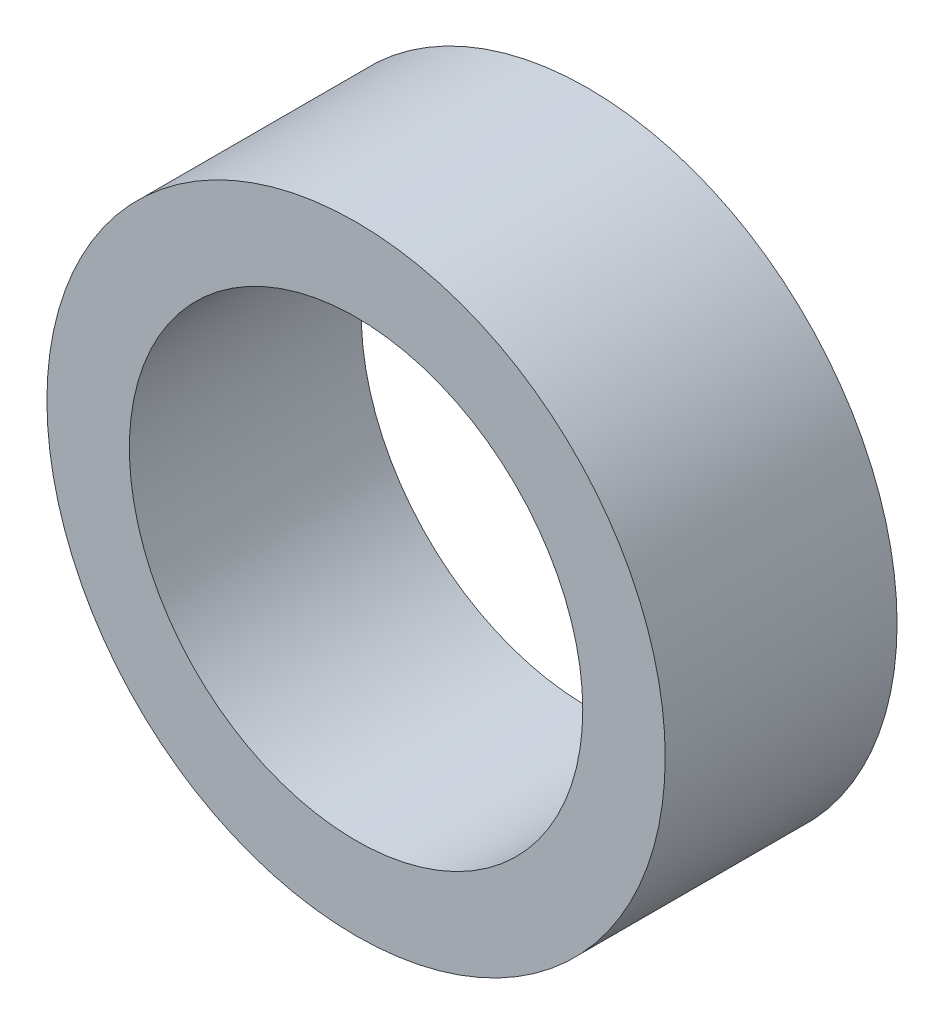
from build123d import *

# Parameters (mm, degrees)
ESBO_O1_R                = 6
ESBO_O1_R_2              = 4.4
RESSALTO_EXTRUS_O1_DEPTH = 4.5


with BuildPart() as part:
    # Esboço1 → Ressalto-extrusão1 (new body)
    with BuildSketch(Plane.XY):
        with Locations((81.932756389, 26.390732255)):
            Circle(ESBO_O1_R)
        with Locations((81.932756389, 26.390732255)):
            Circle(ESBO_O1_R_2, mode=Mode.SUBTRACT)
    extrude(amount=RESSALTO_EXTRUS_O1_DEPTH)


solid = part.part
